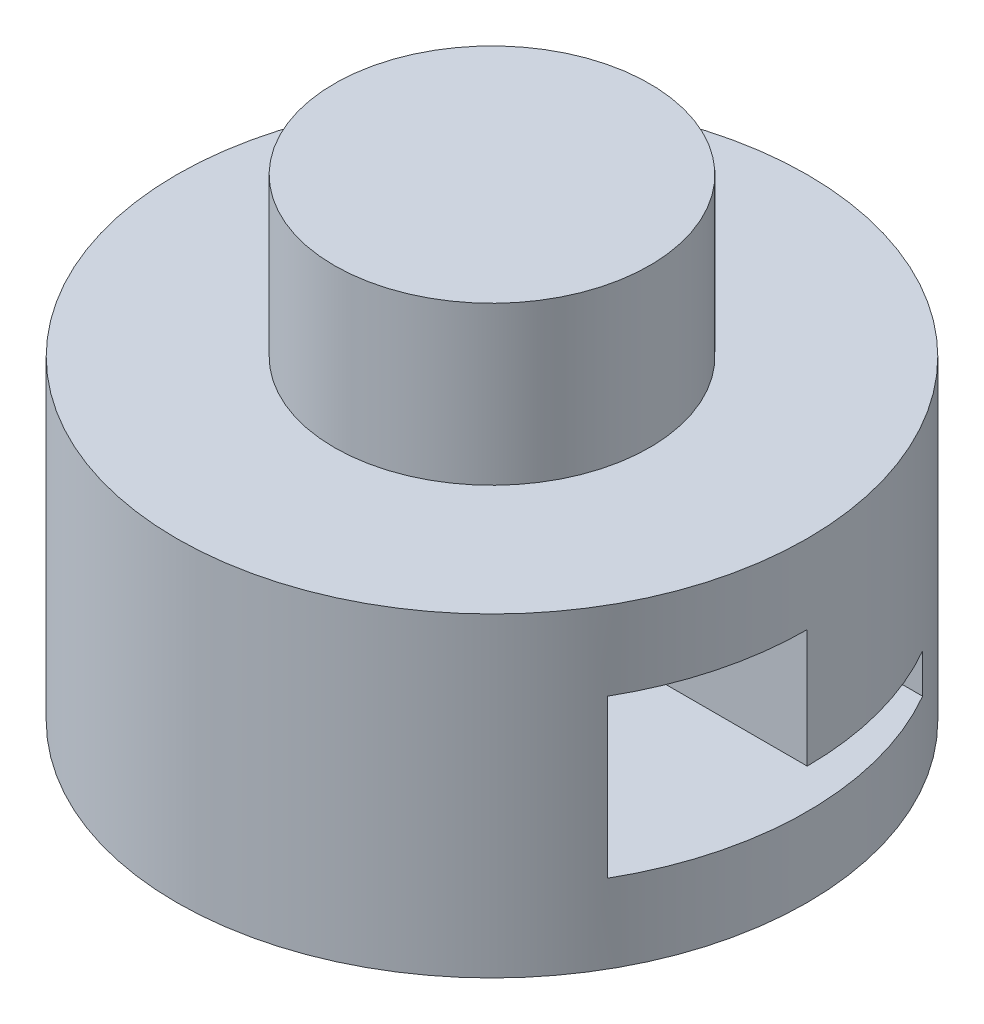
from build123d import *

# Parameters (mm, degrees)
SKETCH3_R               = 25.4
BOSS_EXTRUDE1_DEPTH     = 25.4
SKETCH4_R               = 12.7
BOSS_EXTRUDE2_DEPTH     = 12.7
CUT_EXTRUDE1_DEPTH      = 26.4
CUT_EXTRUDE1_DEPTH_BACK = 26.4


with BuildPart() as part:
    # Sketch3 → Boss-Extrude1 (new body)
    with BuildSketch(Plane(origin=(0, 0, 0), x_dir=(1, 0, 0), z_dir=(0, 1, 0))):
        Circle(SKETCH3_R)
    extrude(amount=BOSS_EXTRUDE1_DEPTH)

    # Sketch4 → Boss-Extrude2 (add)
    with BuildSketch(Plane(origin=(0, 25.4, 0), x_dir=(1, 0, 0), z_dir=(0, 1, 0))):
        Circle(SKETCH4_R)
    extrude(amount=BOSS_EXTRUDE2_DEPTH)

    # Sketch5 → Cut-Extrude1 (cut, two sides)
    with BuildSketch(Plane(origin=(0, 0, 0), x_dir=(0, 0, -1), z_dir=(1, 0, 0))) as cut_extrude1_sk:
        Polygon((12.7, 6.35), (-12.7, 6.35), (-12.7, 19.05), (0, 19.05), (0, 9.525), (12.7, 9.525), align=None)
    extrude(amount=CUT_EXTRUDE1_DEPTH, mode=Mode.SUBTRACT)
    extrude(cut_extrude1_sk.sketch, amount=-CUT_EXTRUDE1_DEPTH_BACK, mode=Mode.SUBTRACT)


solid = part.part
